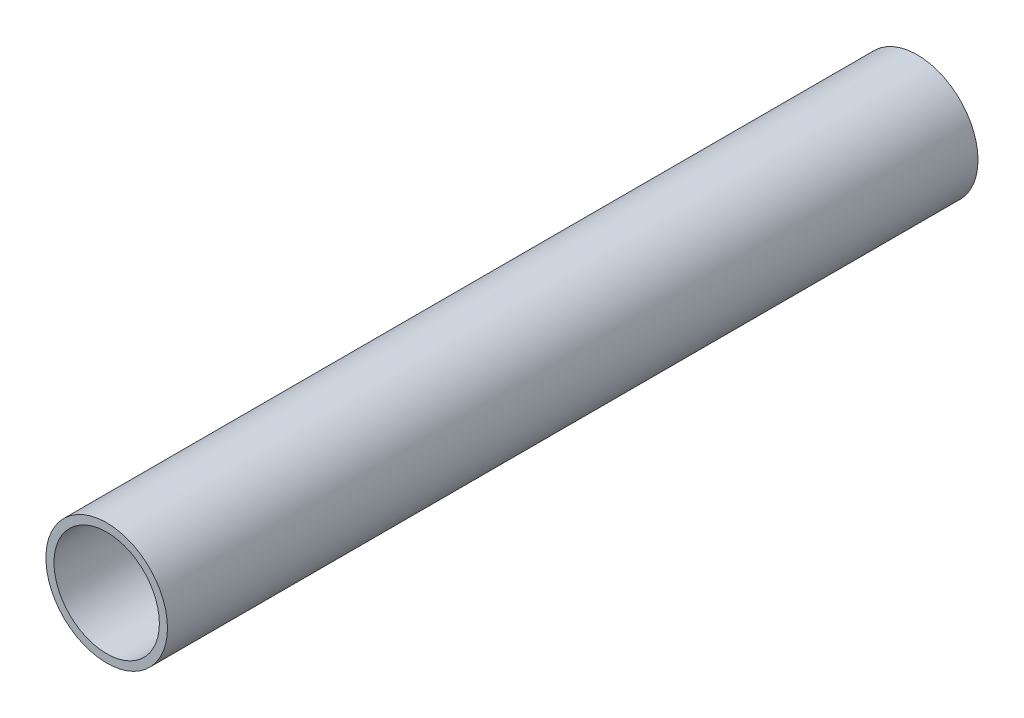
from build123d import *

# Parameters (mm, degrees)
SKETCH1_R           = 75
BOSS_EXTRUDE1_DEPTH = 1000
SKETCH2_R           = 65
CUT_EXTRUDE1_DEPTH  = 1000


with BuildPart() as part:
    # Sketch1 → Boss-Extrude1 (new body)
    with BuildSketch(Plane.XY):
        Circle(SKETCH1_R)
    extrude(amount=BOSS_EXTRUDE1_DEPTH)

    # Sketch2 → Cut-Extrude1 (cut)
    with BuildSketch(Plane.XY.offset(1000)):
        Circle(SKETCH2_R)
    extrude(amount=-CUT_EXTRUDE1_DEPTH, mode=Mode.SUBTRACT)


solid = part.part
